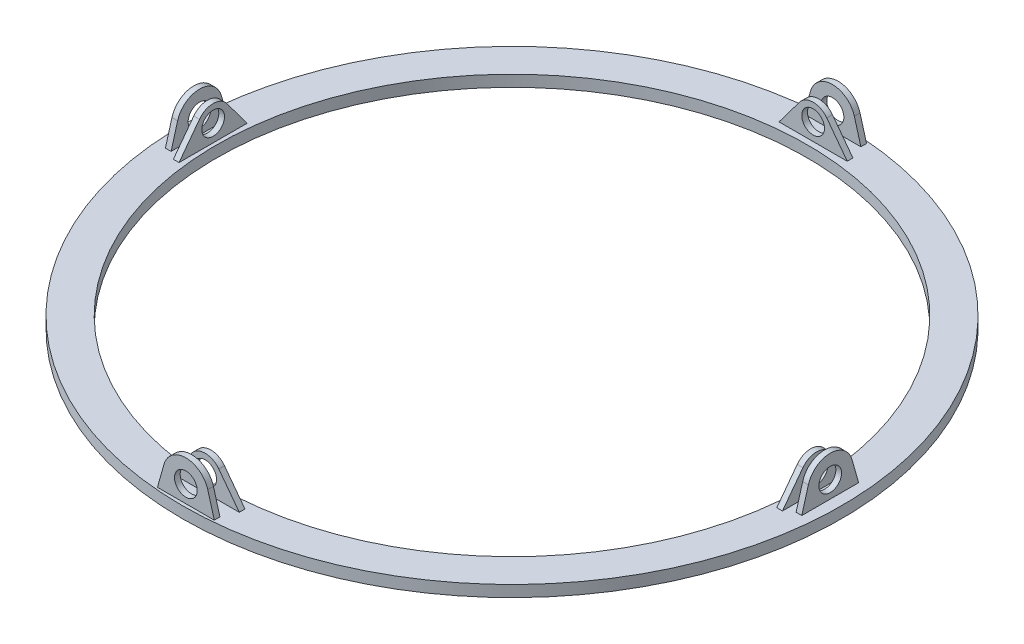
from build123d import *

# Parameters (mm, degrees)
SKETCH1_R           = 145
SKETCH1_R_2         = 130
BOSS_EXTRUDE1_DEPTH = 5
BOSS_EXTRUDE2_START = -10
SKETCH5_R           = 5
BOSS_EXTRUDE2_DEPTH = 2.5
BOSS_EXTRUDE3_START = -1.5
SKETCH6_R           = 5
BOSS_EXTRUDE3_DEPTH = 2.5
BOSS_EXTRUDE4_START = 137.5
SKETCH8_R           = 5
BOSS_EXTRUDE4_DEPTH = 2.5
BOSS_EXTRUDE5_START = 131.5
SKETCH10_R          = 5
BOSS_EXTRUDE5_DEPTH = 2.5


with BuildPart() as part:
    # Sketch1 → Boss-Extrude1 (new body)
    with BuildSketch(Plane(origin=(0, 0, 0), x_dir=(1, 0, 0), z_dir=(0, 1, 0))):
        Circle(SKETCH1_R)
        Circle(SKETCH1_R_2, mode=Mode.SUBTRACT)
    extrude(amount=BOSS_EXTRUDE1_DEPTH)

    # Sketch5 → Boss-Extrude2 (add)
    with BuildSketch(Plane.XY.offset(145).offset(BOSS_EXTRUDE2_START)):
        with BuildLine():
            Line((-15, 5), (15, 5))
            Line((15, 5), (6, 17))
            ThreePointArc((6, 17), (0, 20), (-6, 17))
            Line((-6, 17), (-15, 5))
        make_face()
        with Locations((0, 12.5)):
            Circle(SKETCH5_R, mode=Mode.SUBTRACT)
    boss_extrude2 = extrude(amount=-BOSS_EXTRUDE2_DEPTH)


with BuildPart() as body_2:
    # Sketch6 → Boss-Extrude3 (new body)
    with BuildSketch(Plane.XY.offset(145).offset(BOSS_EXTRUDE3_START)):
        with BuildLine():
            Line((-12.5, 5), (12.5, 5))
            Line((12.5, 5), (9.62585943, 15.209765716))
            ThreePointArc((9.62585943, 15.209765716), (0, 22.5), (-9.62585943, 15.209765716))
            Line((-9.62585943, 15.209765716), (-12.5, 5))
        make_face()
        with Locations((0, 12.5)):
            Circle(SKETCH6_R, mode=Mode.SUBTRACT)
    boss_extrude3 = extrude(amount=-BOSS_EXTRUDE3_DEPTH)


with BuildPart() as part_1:
    add(part.part)

    # Mirror1: Boss-Extrude2, Boss-Extrude3 across plane
    add(boss_extrude2.mirror(Plane.XY))
    add(boss_extrude3.mirror(Plane.XY))

    # Sketch8 → Boss-Extrude4 (add)
    with BuildSketch(Plane(origin=(0, 0, 0), x_dir=(0, 0, -1), z_dir=(1, 0, 0)).offset(BOSS_EXTRUDE4_START)):
        with BuildLine():
            Line((-12.5, 5), (12.5, 5))
            Line((12.5, 5), (9.62585943, 15.209765716))
            ThreePointArc((9.62585943, 15.209765716), (0, 22.5), (-9.62585943, 15.209765716))
            Line((-9.62585943, 15.209765716), (-12.5, 5))
        make_face()
        with Locations((0, 12.5)):
            Circle(SKETCH8_R, mode=Mode.SUBTRACT)
    boss_extrude4 = extrude(amount=BOSS_EXTRUDE4_DEPTH)

    # Sketch10 → Boss-Extrude5 (add)
    with BuildSketch(Plane(origin=(0, 0, 0), x_dir=(0, 0, -1), z_dir=(1, 0, 0)).offset(BOSS_EXTRUDE5_START)):
        with BuildLine():
            Line((-15, 5), (15, 5))
            Line((15, 5), (6, 17))
            ThreePointArc((6, 17), (0, 20), (-6, 17))
            Line((-6, 17), (-15, 5))
        make_face()
        with Locations((0, 12.5)):
            Circle(SKETCH10_R, mode=Mode.SUBTRACT)
    boss_extrude5 = extrude(amount=BOSS_EXTRUDE5_DEPTH)

    # Mirror2: Boss-Extrude4, Boss-Extrude5 across plane
    add(boss_extrude4.mirror(Plane(origin=(0, 0, 0), x_dir=(0, 0, 1), z_dir=(1, 0, 0))))
    add(boss_extrude5.mirror(Plane(origin=(0, 0, 0), x_dir=(0, 0, 1), z_dir=(1, 0, 0))))


solid = Compound([body_2.part, part_1.part])
